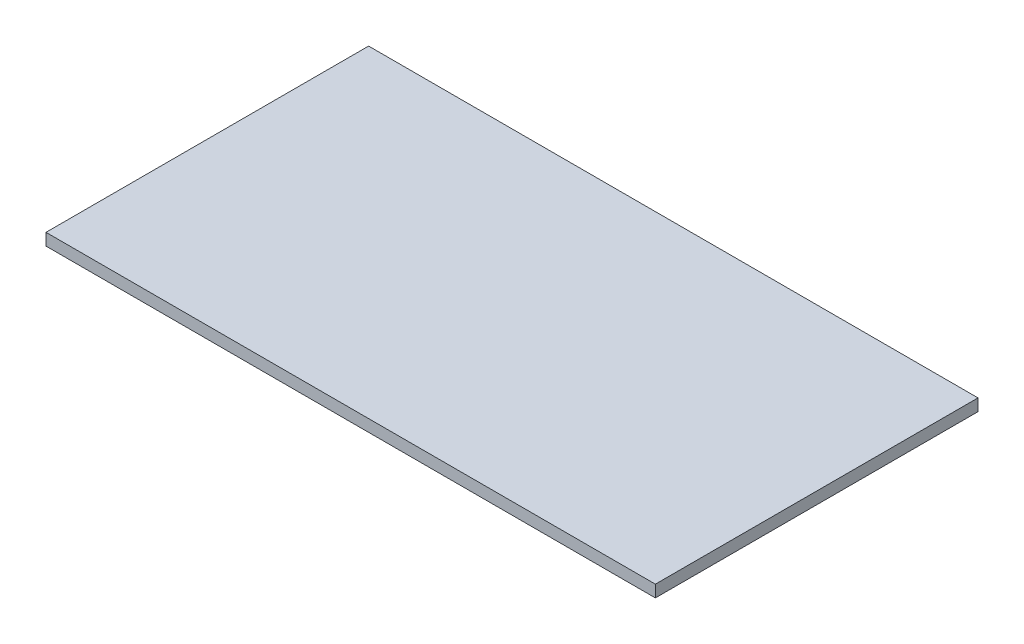
from build123d import *

# Parameters (mm, degrees)
SKETCH1_W           = 510
SKETCH1_H           = 270
BOSS_EXTRUDE1_DEPTH = 10


with BuildPart() as part:
    # Sketch1 → Boss-Extrude1 (new body)
    with BuildSketch(Plane(origin=(0, 0, 0), x_dir=(1, 0, 0), z_dir=(0, 1, 0))):
        Rectangle(SKETCH1_W, SKETCH1_H)
    extrude(amount=BOSS_EXTRUDE1_DEPTH)


solid = part.part
